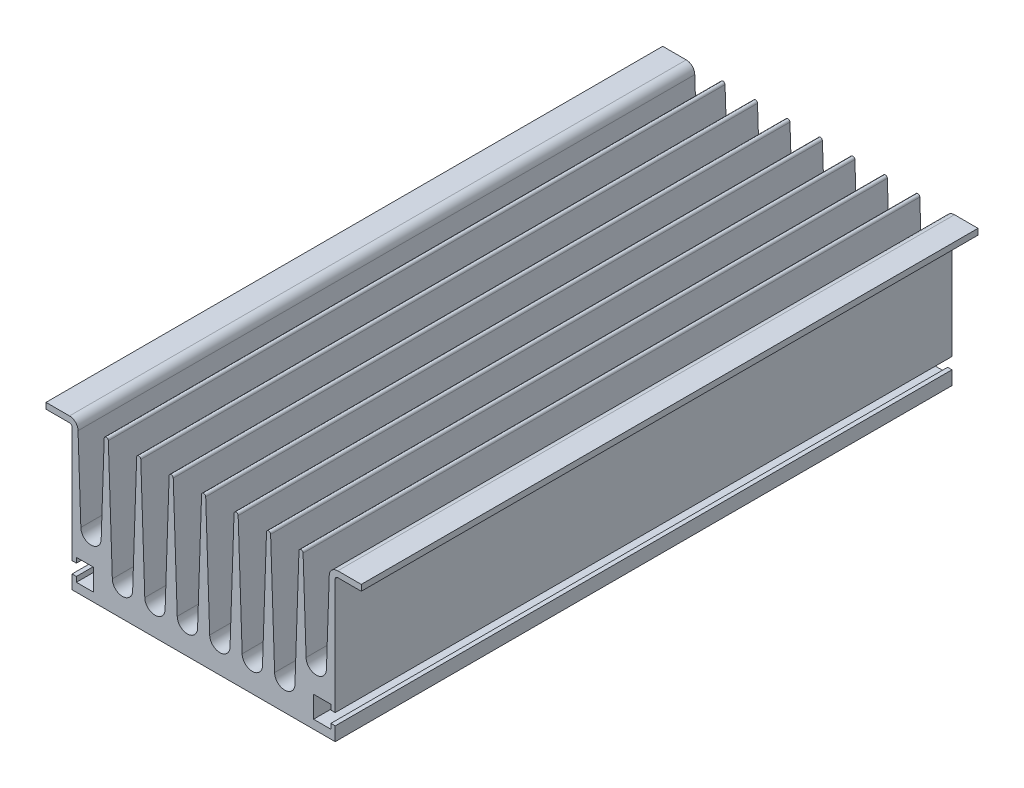
from build123d import *

# Parameters (mm, degrees)
RESSALTO_EXTRUS_O1_DEPTH = 285


with BuildPart() as part:
    # Esboço1 → Ressalto-extrusão1 (new body)
    with BuildSketch(Plane.XY):
        with BuildLine():
            Line((0, 0), (-121.6, 0))
            Line((-121.6, 0), (-121.6, 6.35))
            Line((-121.6, 6.35), (-119.6, 6.35))
            Line((-119.6, 6.35), (-119.6, 4))
            Line((-119.6, 4), (-111.6, 4))
            Line((-111.6, 4), (-111.6, 14))
            Line((-111.6, 14), (-119.6, 14))
            Line((-119.6, 14), (-119.6, 11.65))
            Line((-119.6, 11.65), (-121.6, 11.65))
            Line((-121.6, 11.65), (-121.6, 65.055990081))
            ThreePointArc((-121.6, 65.055990081), (-121.94756763, 65.895092566), (-122.786670115, 66.242660196))
            Line((-122.786670115, 66.242660196), (-133.65, 66.242660196))
            Line((-133.65, 66.242660196), (-133.65, 69))
            Line((-133.65, 69), (-122.786670115, 69))
            ThreePointArc((-122.786670115, 69), (-119.997833956, 67.84482624), (-118.842660196, 65.055990081))
            Line((-118.842660196, 65.055990081), (-117.547286109, 27))
            ThreePointArc((-117.547286109, 27), (-112.847286109, 22.3), (-108.147286109, 27))
            Line((-108.147286109, 27), (-106.75, 68.05))
            ThreePointArc((-106.75, 68.05), (-105.8, 69), (-104.85, 68.05))
            Line((-104.85, 68.05), (-103, 13.7))
            ThreePointArc((-103, 13.7), (-98.3, 9), (-93.6, 13.7))
            Line((-93.6, 13.7), (-91.75, 68.05))
            ThreePointArc((-91.75, 68.05), (-90.8, 69), (-89.85, 68.05))
            Line((-89.85, 68.05), (-88, 13.7))
            ThreePointArc((-88, 13.7), (-83.3, 9), (-78.6, 13.7))
            Line((-78.6, 13.7), (-76.75, 68.05))
            ThreePointArc((-76.75, 68.05), (-75.8, 69), (-74.85, 68.05))
            Line((-74.85, 68.05), (-73, 13.7))
            ThreePointArc((-73, 13.7), (-68.3, 9), (-63.6, 13.7))
            Line((-63.6, 13.7), (-61.75, 68.05))
            ThreePointArc((-61.75, 68.05), (-60.8, 69), (-59.85, 68.05))
            Line((-59.85, 68.05), (-58, 13.7))
            ThreePointArc((-58, 13.7), (-53.3, 9), (-48.6, 13.7))
            Line((-48.6, 13.7), (-46.75, 68.05))
            ThreePointArc((-46.75, 68.05), (-45.8, 69), (-44.85, 68.05))
            Line((-44.85, 68.05), (-43, 13.7))
            ThreePointArc((-43, 13.7), (-38.3, 9), (-33.6, 13.7))
            Line((-33.6, 13.7), (-31.75, 68.05))
            ThreePointArc((-31.75, 68.05), (-30.8, 69), (-29.85, 68.05))
            Line((-29.85, 68.05), (-28, 13.7))
            ThreePointArc((-28, 13.7), (-23.3, 9), (-18.6, 13.7))
            Line((-18.6, 13.7), (-16.75, 68.05))
            ThreePointArc((-16.75, 68.05), (-15.8, 69), (-14.85, 68.05))
            Line((-14.85, 68.05), (-13.452713891, 27))
            ThreePointArc((-13.452713891, 27), (-8.752713891, 22.3), (-4.052713891, 27))
            Line((-4.052713891, 27), (-2.757339804, 65.055990081))
            ThreePointArc((-2.757339804, 65.055990081), (-1.602166044, 67.84482624), (1.186670115, 69))
            Line((1.186670115, 69), (12.05, 69))
            Line((12.05, 69), (12.05, 66.242660196))
            Line((12.05, 66.242660196), (1.186670115, 66.242660196))
            ThreePointArc((1.186670115, 66.242660196), (0.34756763, 65.895092566), (0, 65.055990081))
            Line((0, 65.055990081), (0, 11.65))
            Line((0, 11.65), (-2, 11.65))
            Line((-2, 11.65), (-2, 14))
            Line((-2, 14), (-10, 14))
            Line((-10, 14), (-10, 4))
            Line((-10, 4), (-2, 4))
            Line((-2, 4), (-2, 6.35))
            Line((-2, 6.35), (0, 6.35))
            Line((0, 6.35), (0, 0))
        make_face()
    extrude(amount=RESSALTO_EXTRUS_O1_DEPTH)


solid = part.part
